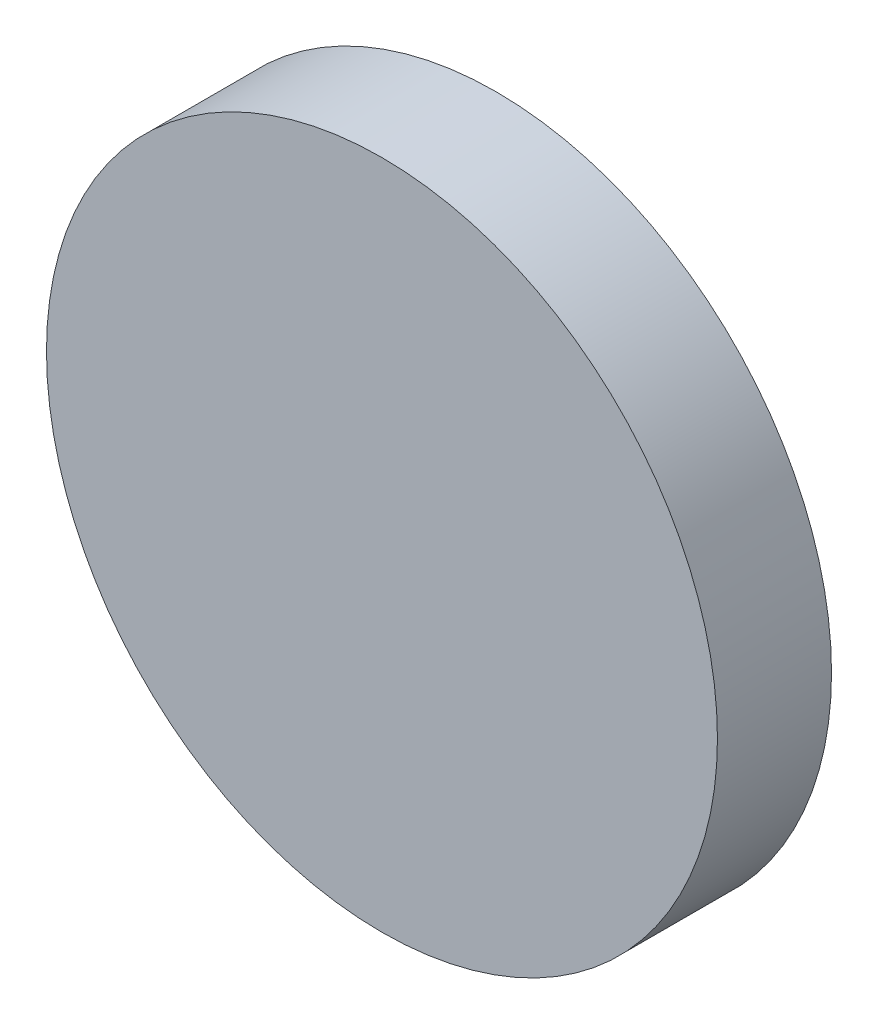
from build123d import *

# Parameters (mm, degrees)
SKETCH1_R           = 25
BOSS_EXTRUDE1_DEPTH = 8.5
SKETCH2_R           = 6
SKETCH2_R_2         = 2.5
BOSS_EXTRUDE2_DEPTH = 10


with BuildPart() as part:
    # Sketch1 → Boss-Extrude1 (new body)
    with BuildSketch(Plane.XY):
        Circle(SKETCH1_R)
    extrude(amount=BOSS_EXTRUDE1_DEPTH)

    # Sketch2 → Boss-Extrude2 (add)
    with BuildSketch(Plane(origin=(0, 0, 0), x_dir=(-1, 0, 0), z_dir=(0, 0, -1))):
        Circle(SKETCH2_R)
        Circle(SKETCH2_R_2, mode=Mode.SUBTRACT)
    extrude(amount=BOSS_EXTRUDE2_DEPTH)


solid = part.part
